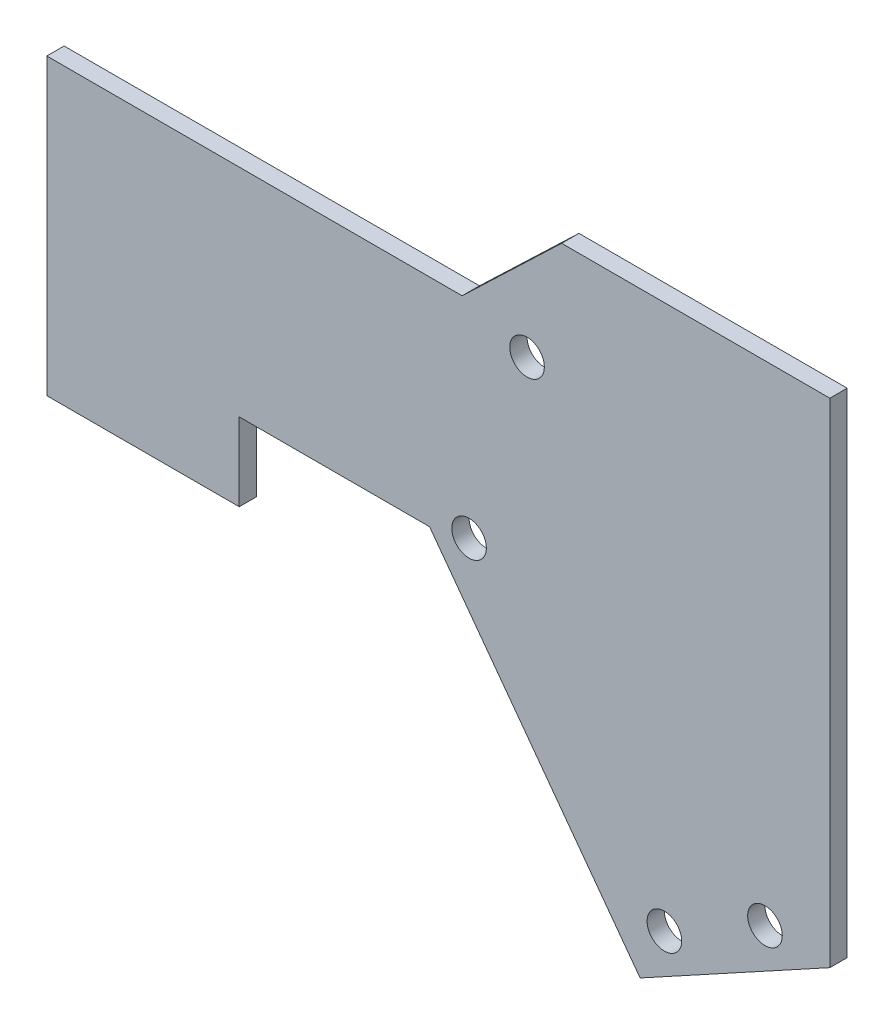
from build123d import *

# Parameters (mm, degrees)
SKETCH1_R           = 12.7
BOSS_EXTRUDE1_DEPTH = 12.7


with BuildPart() as part:
    # Sketch1 → Boss-Extrude1 (new body)
    with BuildSketch(Plane.XY):
        Polygon((0, 0), (0, -361.95), (-139.266372467, -438.15), (-293.768540736, -228.6), (-433.468540736, -228.6), (-433.468540736, -285.75), (-574.675, -285.75), (-574.675, -69.85), (-269.875, -69.85), (-196.85, 0), align=None)
        with Locations((-121.436177407, -399.440649221)):
            Circle(SKETCH1_R, mode=Mode.SUBTRACT)
        with Locations((-47.625, -359.054649221)):
            Circle(SKETCH1_R, mode=Mode.SUBTRACT)
        with Locations((-264.81476339, -221.394191571)):
            Circle(SKETCH1_R, mode=Mode.SUBTRACT)
        with Locations((-222.25, -85.00685146)):
            Circle(SKETCH1_R, mode=Mode.SUBTRACT)
    extrude(amount=BOSS_EXTRUDE1_DEPTH)


solid = part.part
